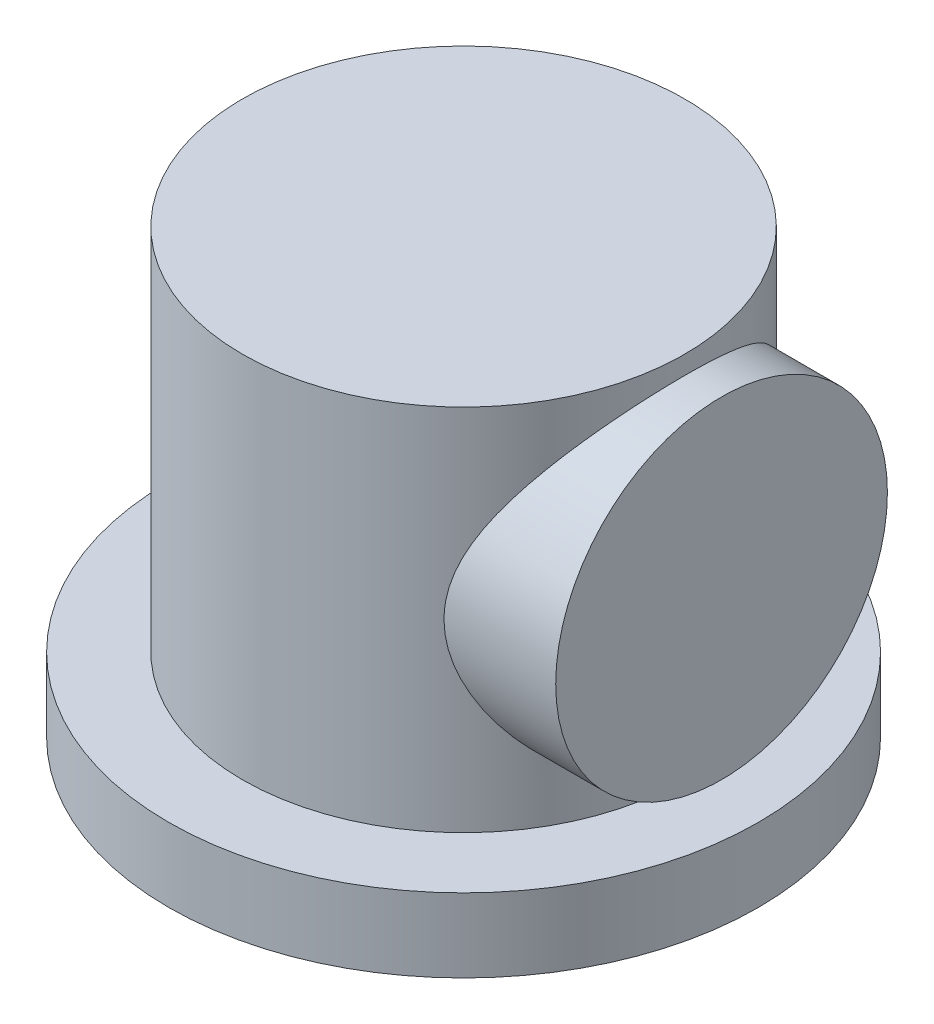
from build123d import *

# Parameters (mm, degrees)
SKETCH1_R           = 50.8
SKETCH1_R_2         = 38.1
BOSS_EXTRUDE1_DEPTH = 12.7
BOSS_EXTRUDE2_START = 12.7
SKETCH1_3_R         = 38.1
BOSS_EXTRUDE2_DEPTH = 63.5
SKETCH2_R           = 28.575
BOSS_EXTRUDE3_DEPTH = 44.45


with BuildPart() as part:
    # Sketch1 → Boss-Extrude1 (new body)
    with BuildSketch(Plane(origin=(0, 0, 0), x_dir=(1, 0, 0), z_dir=(0, 1, 0))):
        with Locations(Location((0, 0, 0), (0, 0, 270))):
            Circle(SKETCH1_R)
        Circle(SKETCH1_R_2, mode=Mode.SUBTRACT)
        Circle(SKETCH1_R_2)
    extrude(amount=BOSS_EXTRUDE1_DEPTH)

    # Sketch1_3 → Boss-Extrude2 (add)
    with BuildSketch(Plane(origin=(0, 0, 0), x_dir=(1, 0, 0), z_dir=(0, 1, 0)).offset(BOSS_EXTRUDE2_START)):
        with Locations(Location((0, 0, 0), (0, 0, 270))):
            Circle(SKETCH1_3_R)
    extrude(amount=BOSS_EXTRUDE2_DEPTH)

    # Sketch2 → Boss-Extrude3 (add)
    with BuildSketch(Plane(origin=(0, 0, 0), x_dir=(0, 0, -1), z_dir=(1, 0, 0))):
        with Locations(Location((0, 44.45, 0), (0, 0, 180))):
            Circle(SKETCH2_R)
    extrude(amount=BOSS_EXTRUDE3_DEPTH)


solid = part.part
